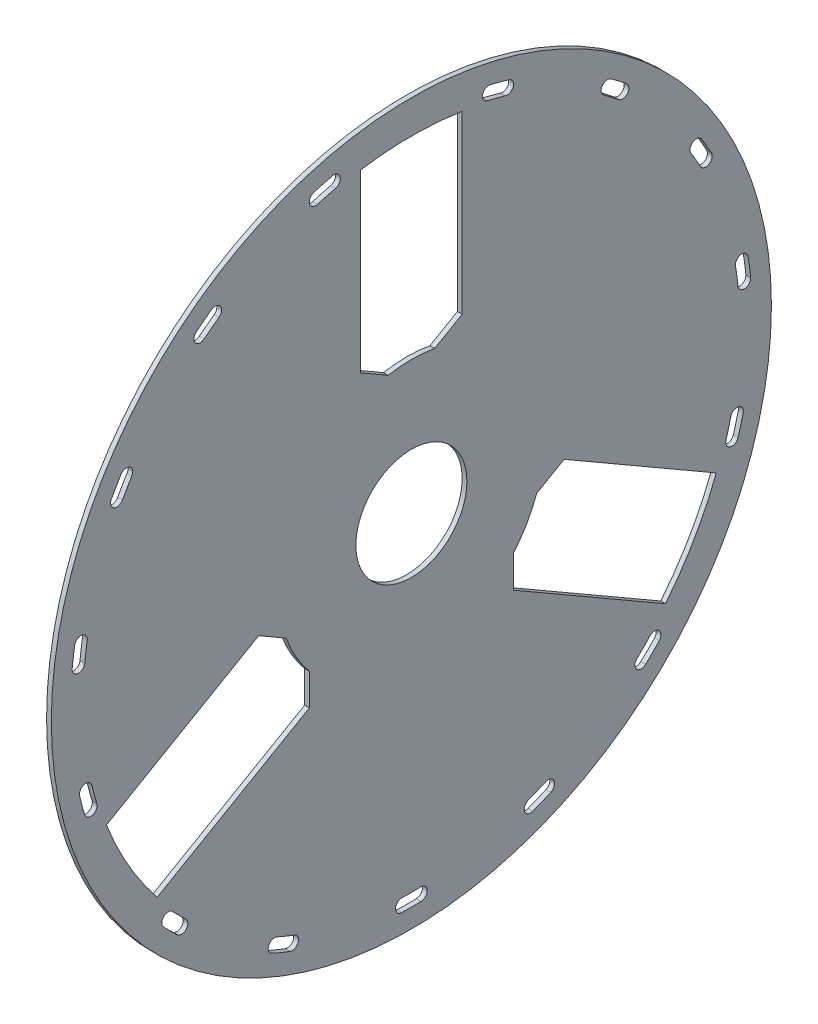
from build123d import *

# Parameters (mm, degrees)
SKETCH_1_R               = 113.5
SKETCH_1_R_2             = 17.5
EXTRUDE_1_DEPTH          = 1.5
CUT_EXTRUDE_1_DEPTH      = 2.5
CUT_EXTRUDE_2_DEPTH      = 2.5
PATTERN_CIRCULAR_1_COUNT = 3


with BuildPart() as part:
    # Эскиз1 → Бобышка-Вытянуть1 (new body)
    with BuildSketch(Plane(origin=(0, 0, 0), x_dir=(0, 0, -1), z_dir=(1, 0, 0))):
        Circle(SKETCH_1_R)
        Circle(SKETCH_1_R_2, mode=Mode.SUBTRACT)
    extrude(amount=EXTRUDE_1_DEPTH)

    # Эскиз2 → Вырез-Вытянуть1 (cut, through all)
    with BuildSketch(Plane.ZY):
        with BuildLine():
            Line((-16, 101.749692874), (-16, 46.353695472))
            Line((-16, 46.353695472), (-7.339745962, 41.353695472))
            ThreePointArc((-7.339745962, 41.353695472), (0, 42), (7.339745962, 41.353695472))
            Line((7.339745962, 41.353695472), (16, 46.353695472))
            Line((16, 46.353695472), (16, 101.749692874))
            ThreePointArc((16, 101.749692874), (0, 103), (-16, 101.749692874))
        make_face()
        with BuildLine():
            Line((96.117818856, -37.018439977), (48.143477838, -9.320441276))
            Line((48.143477838, -9.320441276), (39.4832238, -14.320441276))
            ThreePointArc((39.4832238, -14.320441276), (36.373066959, -21), (32.143477838, -27.033254197))
            Line((32.143477838, -27.033254197), (32.143477838, -37.033254197))
            Line((32.143477838, -37.033254197), (80.117818856, -64.731252898))
            ThreePointArc((80.117818856, -64.731252898), (89.20061659, -51.5), (96.117818856, -37.018439977))
        make_face()
        with BuildLine():
            Line((-80.117818856, -64.731252898), (-32.143477838, -37.033254197))
            Line((-32.143477838, -37.033254197), (-32.143477838, -27.033254197))
            ThreePointArc((-32.143477838, -27.033254197), (-36.373066959, -21), (-39.4832238, -14.320441276))
            Line((-39.4832238, -14.320441276), (-48.143477838, -9.320441276))
            Line((-48.143477838, -9.320441276), (-96.117818856, -37.018439977))
            ThreePointArc((-96.117818856, -37.018439977), (-89.20061659, -51.5), (-80.117818856, -64.731252898))
        make_face()
    extrude(amount=-CUT_EXTRUDE_1_DEPTH, mode=Mode.SUBTRACT)

    # Эскиз3 → Вырез-Вытянуть2 (cut, through all)
    with BuildSketch(Plane.ZY):
        with BuildLine():
            ThreePointArc((-78.144774985, -73.821705091), (-76.013978978, -76.013978978), (-73.821705091, -78.144774985))
            ThreePointArc((-73.821705091, -78.144774985), (-70.994421741, -78.064345778), (-71.074850948, -75.237062428))
            ThreePointArc((-71.074850948, -75.237062428), (-73.185551853, -73.185551853), (-75.237062428, -71.074850948))
            ThreePointArc((-75.237062428, -71.074850948), (-78.064345778, -70.994421741), (-78.144774985, -73.821705091))
        make_face()
        with BuildLine():
            ThreePointArc((-43.946014694, -98.107073101), (-41.138468979, -99.317049745), (-38.297651676, -100.446701669))
            ThreePointArc((-38.297651676, -100.446701669), (-35.716361381, -99.290440274), (-36.872622776, -96.709149979))
            ThreePointArc((-36.872622776, -96.709149979), (-39.60773525, -95.621531615), (-42.310814148, -94.456577358))
            ThreePointArc((-42.310814148, -94.456577358), (-44.953662293, -95.464224956), (-43.946014694, -98.107073101))
        make_face()
        with BuildLine():
            ThreePointArc((-3.056872038, -107.456528575), (0, -107.5), (3.056872038, -107.456528575))
            ThreePointArc((3.056872038, -107.456528575), (4.999191229, -105.400465308), (2.943127962, -103.458146116))
            ThreePointArc((2.943127962, -103.458146116), (0, -103.5), (-2.943127962, -103.458146116))
            ThreePointArc((-2.943127962, -103.458146116), (-4.999191229, -105.400465308), (-3.056872038, -107.456528575))
        make_face()
        with BuildLine():
            ThreePointArc((43.946014694, -98.107073101), (41.138468979, -99.317049745), (38.297651676, -100.446701669))
            ThreePointArc((38.297651676, -100.446701669), (35.716361381, -99.290440274), (36.872622776, -96.709149979))
            ThreePointArc((36.872622776, -96.709149979), (39.60773525, -95.621531615), (42.310814148, -94.456577358))
            ThreePointArc((42.310814148, -94.456577358), (44.953662293, -95.464224956), (43.946014694, -98.107073101))
        make_face()
        with BuildLine():
            ThreePointArc((78.144774985, -73.821705091), (76.013978978, -76.013978978), (73.821705091, -78.144774985))
            ThreePointArc((73.821705091, -78.144774985), (70.994421741, -78.064345778), (71.074850948, -75.237062428))
            ThreePointArc((71.074850948, -75.237062428), (73.185551853, -73.185551853), (75.237062428, -71.074850948))
            ThreePointArc((75.237062428, -71.074850948), (78.064345778, -70.994421741), (78.144774985, -73.821705091))
        make_face()
    cut_extrude_2 = extrude(amount=-CUT_EXTRUDE_2_DEPTH, mode=Mode.SUBTRACT)

    # Круговой массив1: Вырез-Вытянуть2 ×3 about axis
    pattern_circular_1_axis = Axis((0, 0, 0), (1, 0, 0))
    for i in range(1, PATTERN_CIRCULAR_1_COUNT):
        add(cut_extrude_2.rotate(pattern_circular_1_axis, i * 360 / PATTERN_CIRCULAR_1_COUNT), mode=Mode.SUBTRACT)


solid = part.part
